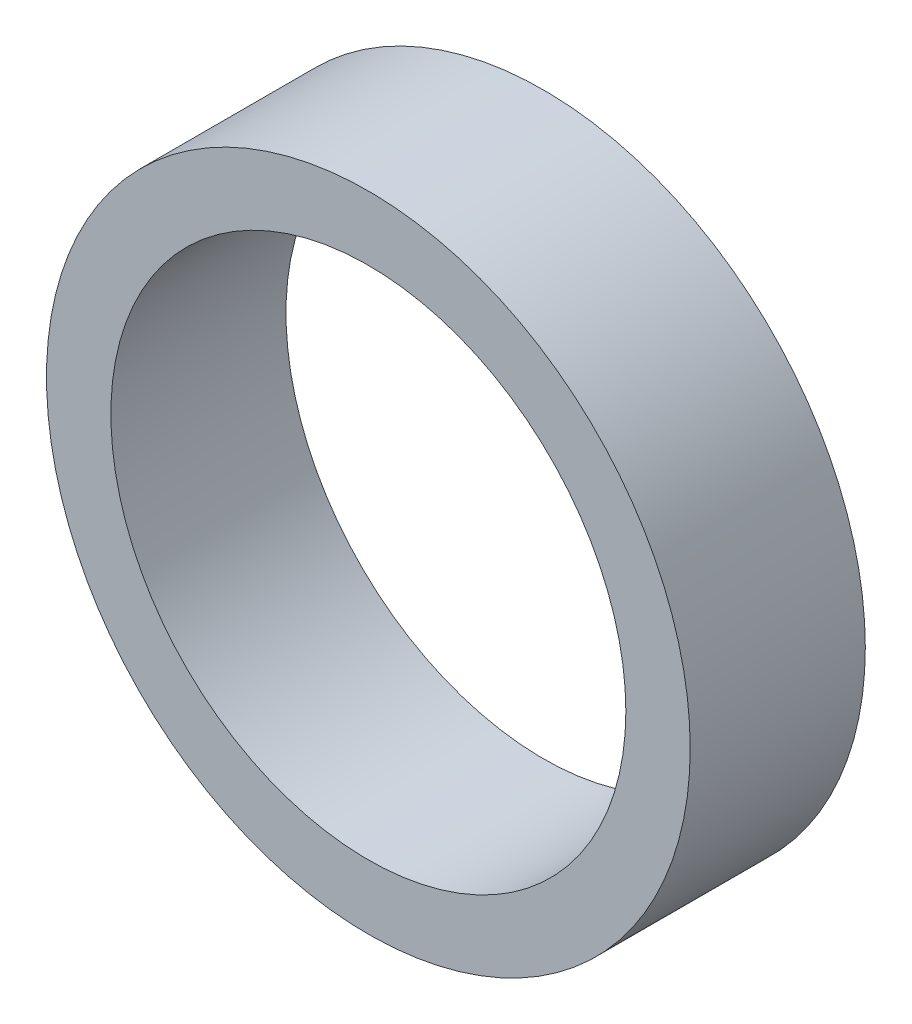
from build123d import *

# Parameters (mm, degrees)
SKETCH1_R      = 3.96875
SKETCH1_R_2    = 3.175
EXTRUDE1_DEPTH = 2.159


with BuildPart() as part:
    # Sketch1 → Extrude1 (new body)
    with BuildSketch(Plane.XY):
        Circle(SKETCH1_R)
        Circle(SKETCH1_R_2, mode=Mode.SUBTRACT)
    extrude(amount=EXTRUDE1_DEPTH)


solid = part.part
